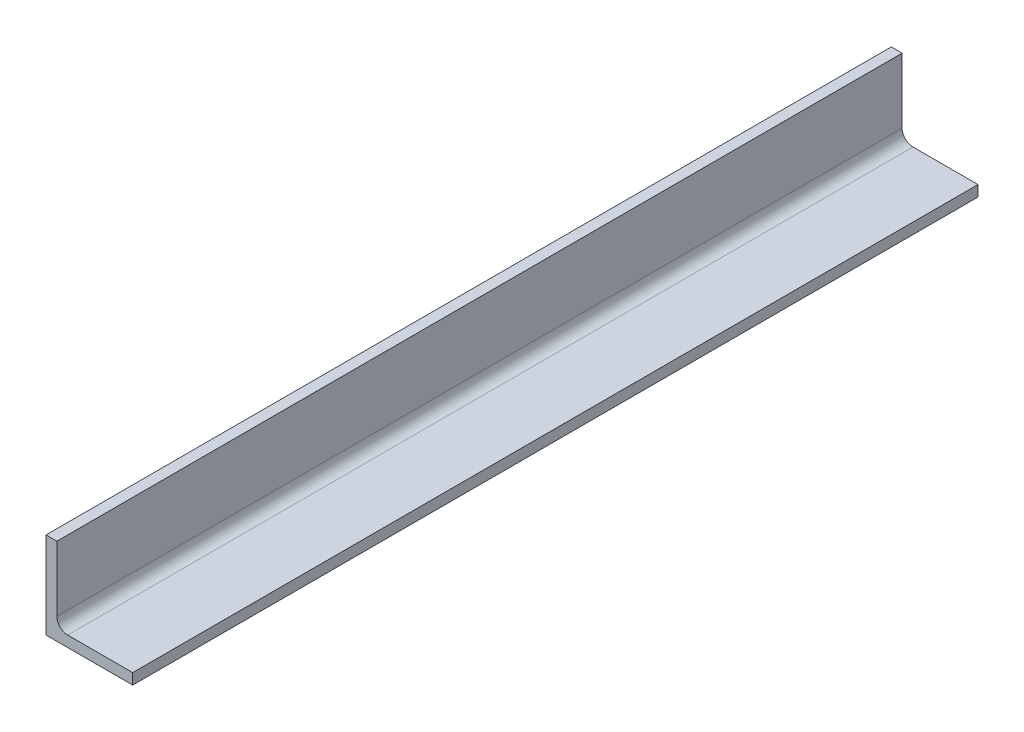
from build123d import *

# Parameters (mm, degrees)
BOSS_EXTRUDE1_DEPTH = 123.83
FILLET1_R           = 3.175


with BuildPart() as part:
    # Sketch1 → Boss-Extrude1 (new body, symmetric)
    with BuildSketch(Plane.XY):
        Polygon((0, 25.4), (0, 0), (25.4, 0), (25.4, 3.175), (3.175, 3.175), (3.175, 25.4), align=None)
    extrude(amount=BOSS_EXTRUDE1_DEPTH, both=True)

    # Fillet1
    fillet1_edges = [part.edges().sort_by_distance(p)[0] for p in [
        (3.175, 3.175, 0),
    ]]
    fillet(fillet1_edges, radius=FILLET1_R)


solid = part.part
